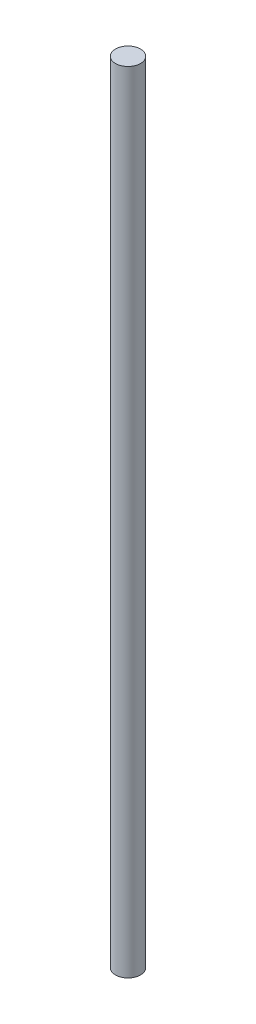
from build123d import *

# Parameters (mm, degrees)
SKETCH1_R           = 3.175
BOSS_EXTRUDE1_DEPTH = 200


with BuildPart() as part:
    # Sketch1 → Boss-Extrude1 (new body)
    with BuildSketch(Plane(origin=(0, 0, 0), x_dir=(1, 0, 0), z_dir=(0, 1, 0))):
        Circle(SKETCH1_R)
    extrude(amount=BOSS_EXTRUDE1_DEPTH)


solid = part.part
